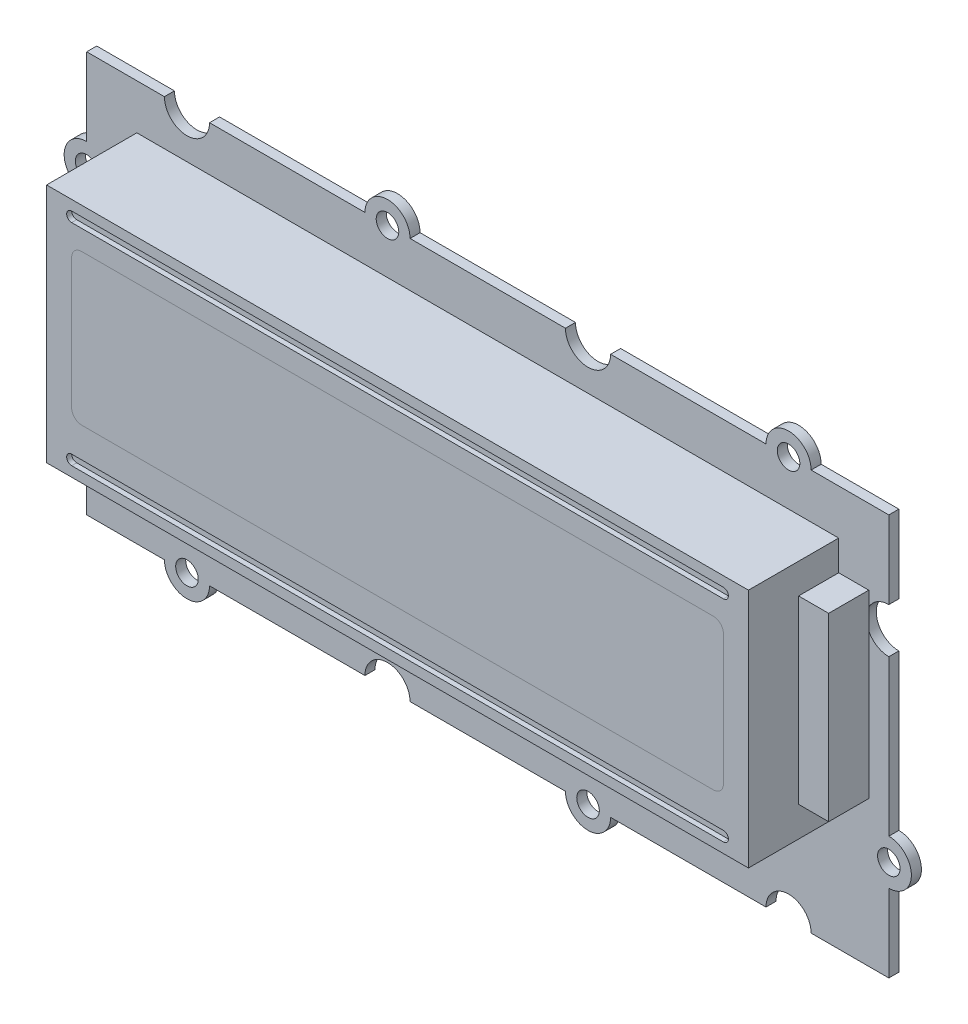
from build123d import *

# Parameters (mm, degrees)
ESQUISSE1_R             = 1.125
BOSS_EXTRU_1_DEPTH      = 1
ESQUISSE2_W             = 70
ESQUISSE2_H             = 24
BOSS_EXTRU_2_DEPTH      = 9
ENL_V_MAT_EXTRU_1_DEPTH = 0.5
BOSS_EXTRU_4_DEPTH      = 1
ESQUISSE5_W             = 4
ESQUISSE5_H             = 18
BOSS_EXTRU_5_DEPTH      = 3


with BuildPart() as part:
    # Esquisse1 → Boss.-Extru.1 (new body)
    with BuildSketch(Plane.XY):
        with BuildLine():
            Line((-40, 20), (-32.25, 20))
            ThreePointArc((-32.25, 20), (-30, 17.75), (-27.75, 20))
            Line((-27.75, 20), (-12.25, 20))
            ThreePointArc((-12.25, 20), (-10, 22.25), (-7.75, 20))
            Line((-7.75, 20), (7.75, 20))
            ThreePointArc((7.75, 20), (10, 17.75), (12.25, 20))
            Line((12.25, 20), (27.75, 20))
            ThreePointArc((27.75, 20), (30, 22.25), (32.25, 20))
            Line((32.25, 20), (40, 20))
            Line((40, 20), (40, 12.25))
            ThreePointArc((40, 12.25), (37.75, 10), (40, 7.75))
            Line((40, 7.75), (40, -7.75))
            ThreePointArc((40, -7.75), (42.25, -10), (40, -12.25))
            Line((40, -12.25), (40, -20))
            Line((40, -20), (32.25, -20))
            ThreePointArc((32.25, -20), (30, -17.75), (27.75, -20))
            Line((27.75, -20), (12.25, -20))
            ThreePointArc((12.25, -20), (10, -22.25), (7.75, -20))
            Line((7.75, -20), (-7.75, -20))
            ThreePointArc((-7.75, -20), (-10, -17.75), (-12.25, -20))
            Line((-12.25, -20), (-27.75, -20))
            ThreePointArc((-27.75, -20), (-30, -22.25), (-32.25, -20))
            Line((-32.25, -20), (-40, -20))
            Line((-40, -20), (-40, -12.25))
            ThreePointArc((-40, -12.25), (-37.75, -10), (-40, -7.75))
            Line((-40, -7.75), (-40, 7.75))
            ThreePointArc((-40, 7.75), (-42.25, 10), (-40, 12.25))
            Line((-40, 12.25), (-40, 20))
        make_face()
        with Locations((-10, 20)):
            Circle(ESQUISSE1_R, mode=Mode.SUBTRACT)
        with Locations((30, 20)):
            Circle(ESQUISSE1_R, mode=Mode.SUBTRACT)
        with Locations((-40, 10)):
            Circle(ESQUISSE1_R, mode=Mode.SUBTRACT)
        with Locations((40, -10)):
            Circle(ESQUISSE1_R, mode=Mode.SUBTRACT)
        with Locations((10, -20)):
            Circle(ESQUISSE1_R, mode=Mode.SUBTRACT)
        with Locations((-30, -20)):
            Circle(ESQUISSE1_R, mode=Mode.SUBTRACT)
    extrude(amount=BOSS_EXTRU_1_DEPTH)

    # Esquisse2 → Boss.-Extru.2 (add)
    with BuildSketch(Plane.XY.offset(1)):
        with Locations((0, 3.5)):
            Rectangle(ESQUISSE2_W, ESQUISSE2_H)
        with BuildLine():
            Line((-31.5, 11.5), (31.5, 11.5))
            ThreePointArc((31.5, 11.5), (32.207106781, 11.207106781), (32.5, 10.5))
            Line((32.5, 10.5), (32.5, -2.5))
            ThreePointArc((32.5, -2.5), (32.207106781, -3.207106781), (31.5, -3.5))
            Line((31.5, -3.5), (-31.5, -3.5))
            ThreePointArc((-31.5, -3.5), (-32.207106781, -3.207106781), (-32.5, -2.5))
            Line((-32.5, -2.5), (-32.5, 10.5))
            ThreePointArc((-32.5, 10.5), (-32.207106781, 11.207106781), (-31.5, 11.5))
        make_face(mode=Mode.SUBTRACT)
    extrude(amount=BOSS_EXTRU_2_DEPTH)

    # Esquisse3 → Enlèv. mat.-Extru.1 (cut)
    with BuildSketch(Plane.XY.offset(10)):
        with BuildLine():
            Line((-32.5, 14.5), (32.5, 14.5))
            ThreePointArc((32.5, 14.5), (33, 14), (32.5, 13.5))
            Line((32.5, 13.5), (-32.5, 13.5))
            ThreePointArc((-32.5, 13.5), (-33, 14), (-32.5, 14.5))
        make_face()
        with BuildLine():
            Line((-32.5, -6.5), (32.5, -6.5))
            ThreePointArc((32.5, -6.5), (33, -7), (32.5, -7.5))
            Line((32.5, -7.5), (-32.5, -7.5))
            ThreePointArc((-32.5, -7.5), (-33, -7), (-32.5, -6.5))
        make_face()
    extrude(amount=-ENL_V_MAT_EXTRU_1_DEPTH, mode=Mode.SUBTRACT)

    # Esquisse5 → Boss.-Extru.5 (add)
    with BuildSketch(Plane(origin=(35, 0, 0), x_dir=(0, 0, -1), z_dir=(1, 0, 0))):
        with Locations((-3, 3.5)):
            Rectangle(ESQUISSE5_W, ESQUISSE5_H)
    extrude(amount=BOSS_EXTRU_5_DEPTH)


with BuildPart() as body_2:
    # Esquisse4 → Boss.-Extru.4 (new body)
    with BuildSketch(Plane.XY.offset(10)):
        with BuildLine():
            Line((32.5, -2.5), (32.5, 10.5))
            ThreePointArc((32.5, 10.5), (32.207106781, 11.207106781), (31.5, 11.5))
            Line((31.5, 11.5), (-31.5, 11.5))
            ThreePointArc((-31.5, 11.5), (-32.207106781, 11.207106781), (-32.5, 10.5))
            Line((-32.5, 10.5), (-32.5, -2.5))
            ThreePointArc((-32.5, -2.5), (-32.207106781, -3.207106781), (-31.5, -3.5))
            Line((-31.5, -3.5), (31.5, -3.5))
            ThreePointArc((31.5, -3.5), (32.207106781, -3.207106781), (32.5, -2.5))
        make_face()
    extrude(amount=-BOSS_EXTRU_4_DEPTH)


solid = Compound([part.part, body_2.part])
